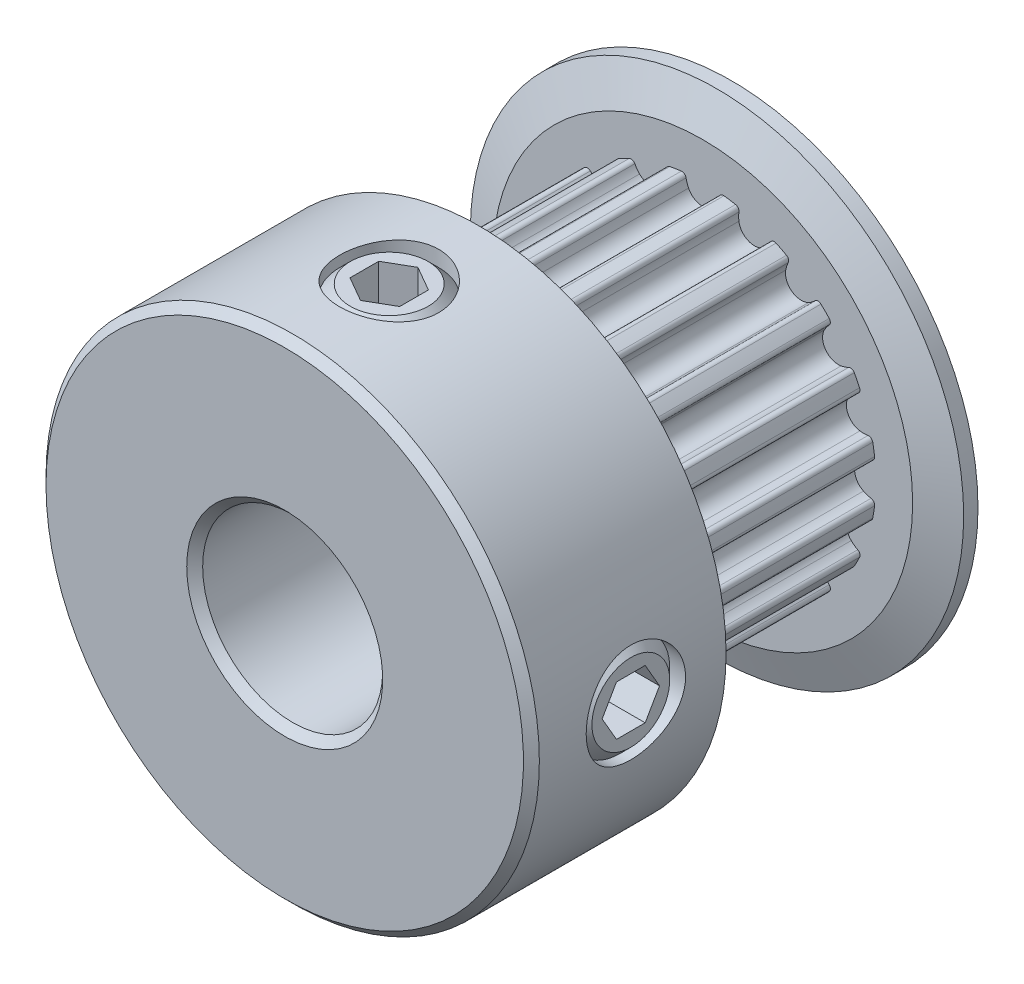
from build123d import *

# Parameters (mm, degrees)
CUT_EXTRUDE1_START = 0.505
CUT_EXTRUDE1_DEPTH = 7.37
CIRPATTERN1_COUNT  = 20
SKETCH4_R          = 1.7526
CUT_EXTRUDE2_DEPTH = 15.607471564
CUT_EXTRUDE3_DEPTH = 1.31445
CIRPATTERN3_COUNT  = 2
CIRPATTERN3_ANGLE  = 90
CHAMFER1_SIZE      = 0.28075


with BuildPart() as part:
    # Sketch2 → Revolve1 (revolve)
    with BuildSketch(Plane(origin=(0, 0, 0), x_dir=(0, 0, -1), z_dir=(1, 0, 0)), mode=Mode.PRIVATE) as revolve1_sk:
        Polygon((-7.875, 3.175), (7.875, 3.175), (7.875, 8.6995), (7.37, 8.6995), (6.865, 7.404), (6.865, 6.1085), (-0.505, 6.1085), (-0.505, 7.404), (-1.01, 8.6995), (-7.875, 8.6995), align=None)
    revolve(revolve1_sk.sketch.rotate(Axis((0, 0, 7.875), (0, 0, -1)), 90), axis=Axis((0, 0, 7.875), (0, 0, -1)))

    # Sketch3 → Cut-Extrude1 (cut)
    with BuildSketch(Plane.XY.offset(CUT_EXTRUDE1_START)):
        with BuildLine():
            Line((2.840989707, 8.6995), (-2.840989707, 8.6995))
            Line((-2.840989707, 8.6995), (-1.896292335, 5.806707124))
            ThreePointArc((-1.896292335, 5.806707124), (-1.330166224, 5.961914966), (-0.751756185, 6.062065233))
            ThreePointArc((-0.751756185, 6.062065233), (-0.643911332, 6.033664451), (-0.58547487, 5.93867868))
            ThreePointArc((-0.58547487, 5.93867868), (-0.551683777, 5.801420225), (-0.498876404, 5.670297753))
            ThreePointArc((-0.498876404, 5.670297753), (0, 5.3585), (0.498876404, 5.670297753))
            ThreePointArc((0.498876404, 5.670297753), (0.551683777, 5.801420225), (0.58547487, 5.93867868))
            ThreePointArc((0.58547487, 5.93867868), (0.643911332, 6.033664451), (0.751756185, 6.062065233))
            ThreePointArc((0.751756185, 6.062065233), (1.330166224, 5.961914966), (1.896292335, 5.806707124))
            Line((1.896292335, 5.806707124), (2.840989707, 8.6995))
        make_face()
    cut_extrude1 = extrude(amount=-CUT_EXTRUDE1_DEPTH, mode=Mode.SUBTRACT)

    # CirPattern1: Cut-Extrude1 ×20 about axis
    cirpattern1_axis = Axis((0, 0, 0), (0, 0, 1))
    for i in range(1, CIRPATTERN1_COUNT):
        add(cut_extrude1.rotate(cirpattern1_axis, i * 360 / CIRPATTERN1_COUNT), mode=Mode.SUBTRACT)

    # Sketch4 → Cut-Extrude2 (cut, through all)
    with BuildSketch(Plane(origin=(0, 0, 0), x_dir=(0, -1, 0), z_dir=(1, 0, 0))):
        with Locations(Location((0, -4.19, 0), (0, 0, 270))):
            Circle(SKETCH4_R)
    cut_extrude2 = extrude(amount=CUT_EXTRUDE2_DEPTH, mode=Mode.SUBTRACT)

    # Sketch5 → Revolve2 (revolve)
    with BuildSketch(Plane.XY.offset(4.19), mode=Mode.PRIVATE) as revolve2_sk:
        Polygon((3.175, -1.3716), (3.175, 0), (8.521132172, 0), (8.521132172, -1.3716), (8.140132172, -1.7526), (3.556, -1.7526), align=None)
    revolve2 = revolve(revolve2_sk.sketch.rotate(Axis((3.175, 0, 4.19), (1, 0, 0)), 270), axis=Axis((3.175, 0, 4.19), (1, 0, 0)))

    # Sketch6 → Cut-Extrude3 (cut)
    with BuildSketch(Plane(origin=(8.521132172, 5.384140679, 0), x_dir=(0, -1, 0), z_dir=(-1, 0, 0))):
        Polygon((5.384140679, 5.201864082), (4.507840679, 4.695932041), (4.507840679, 3.684067959), (5.384140679, 3.178135918), (6.260440679, 3.684067959), (6.260440679, 4.695932041), align=None)
    cut_extrude3 = extrude(amount=CUT_EXTRUDE3_DEPTH, mode=Mode.SUBTRACT)

    # CirPattern3: Cut-Extrude2, Revolve2, Cut-Extrude3 ×2 about axis
    cirpattern3_axis = Axis((0, 0, 0), (0, 0, 1))
    add([cut_extrude2.rotate(cirpattern3_axis, i * CIRPATTERN3_ANGLE / (CIRPATTERN3_COUNT - 1)) for i in range(1, CIRPATTERN3_COUNT)], mode=Mode.SUBTRACT)
    add([revolve2.rotate(cirpattern3_axis, i * CIRPATTERN3_ANGLE / (CIRPATTERN3_COUNT - 1)) for i in range(1, CIRPATTERN3_COUNT)])
    add([cut_extrude3.rotate(cirpattern3_axis, i * CIRPATTERN3_ANGLE / (CIRPATTERN3_COUNT - 1)) for i in range(1, CIRPATTERN3_COUNT)], mode=Mode.SUBTRACT)

    # Chamfer1
    chamfer1_edges = [part.edges().sort_by_distance(p)[0] for p in [
        (-3.175, 0, 7.875),
        (-8.6995, 0, 7.875),
    ]]
    chamfer(chamfer1_edges, length=CHAMFER1_SIZE)


solid = part.part
